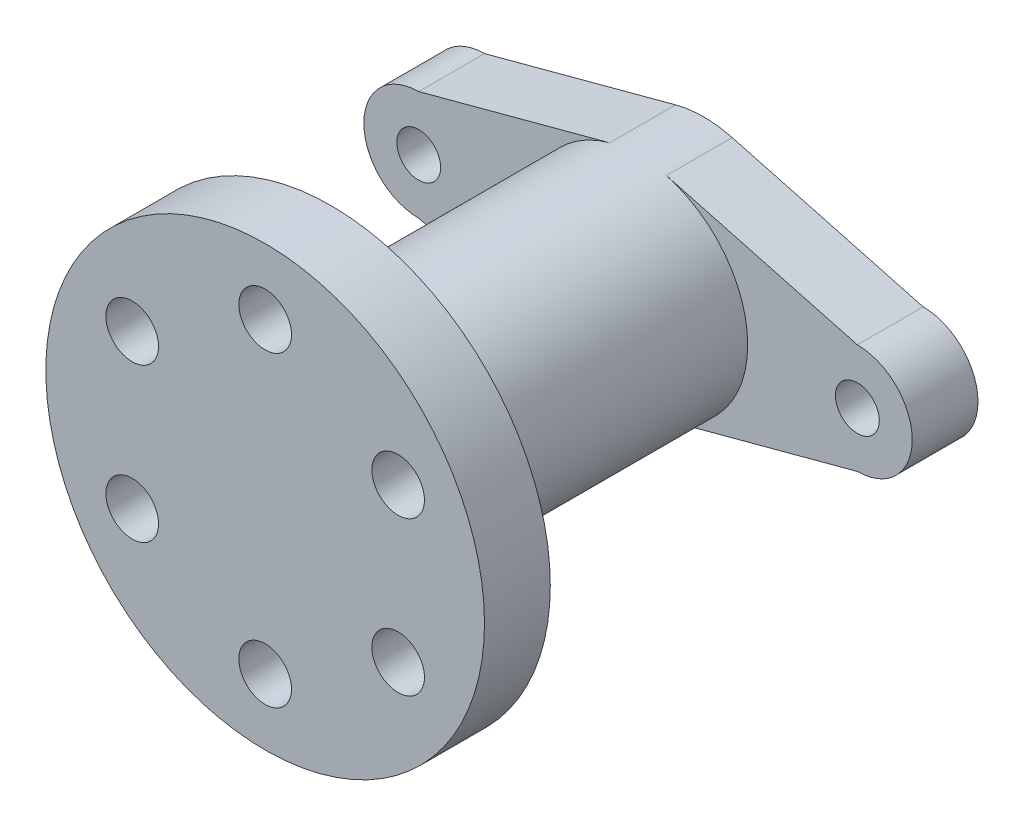
from build123d import *

# Parameters (mm, degrees)
SKETCH1_R           = 50
BOSS_EXTRUDE1_DEPTH = 15
SKETCH2_R           = 25
BOSS_EXTRUDE2_DEPTH = 70
BOSS_EXTRUDE3_DEPTH = 15
SKETCH5_R           = 15
CUT_EXTRUDE1_DEPTH  = 85
SKETCH6_R           = 5
CUT_EXTRUDE2_DEPTH  = 30
SKETCH7_R           = 6
CUT_EXTRUDE3_DEPTH  = 30


with BuildPart() as part:
    # Sketch1 → Boss-Extrude1 (new body)
    with BuildSketch(Plane.XY):
        Circle(SKETCH1_R)
    extrude(amount=BOSS_EXTRUDE1_DEPTH)

    # Sketch2 → Boss-Extrude2 (add)
    with BuildSketch(Plane(origin=(0, 0, 0), x_dir=(-1, 0, 0), z_dir=(0, 0, -1))):
        Circle(SKETCH2_R)
    extrude(amount=BOSS_EXTRUDE2_DEPTH)

    # Sketch4 → Boss-Extrude3 (add)
    with BuildSketch(Plane(origin=(0, 0, -70), x_dir=(-1, 0, 0), z_dir=(0, 0, -1))):
        with BuildLine():
            Line((-50, 12.5), (-6.462424595, 24.15030162))
            ThreePointArc((-6.462424595, 24.15030162), (0, 25), (6.462424595, 24.15030162))
            Line((6.462424595, 24.15030162), (50, 12.5))
            ThreePointArc((50, 12.5), (62.5, 0), (50, -12.5))
            Line((50, -12.5), (6.462424595, -24.15030162))
            ThreePointArc((6.462424595, -24.15030162), (0, -25), (-6.462424595, -24.15030162))
            Line((-6.462424595, -24.15030162), (-50, -12.5))
            ThreePointArc((-50, -12.5), (-62.5, 0), (-50, 12.5))
        make_face()
    extrude(amount=BOSS_EXTRUDE3_DEPTH)

    # Sketch5 → Cut-Extrude1 (cut)
    with BuildSketch(Plane(origin=(0, 0, -85), x_dir=(-1, 0, 0), z_dir=(0, 0, -1))):
        Circle(SKETCH5_R)
    extrude(amount=-CUT_EXTRUDE1_DEPTH, mode=Mode.SUBTRACT)

    # Sketch6 → Cut-Extrude2 (cut)
    with BuildSketch(Plane(origin=(0, 0, -85), x_dir=(-1, 0, 0), z_dir=(0, 0, -1))):
        with Locations((50, 0)):
            Circle(SKETCH6_R)
        with Locations((-50, 0)):
            Circle(SKETCH6_R)
    extrude(amount=-CUT_EXTRUDE2_DEPTH, mode=Mode.SUBTRACT)

    # Sketch7 → Cut-Extrude3 (cut)
    with BuildSketch(Plane(origin=(0, 0, 0), x_dir=(-1, 0, 0), z_dir=(0, 0, -1))):
        with Locations((0, 35)):
            Circle(SKETCH7_R)
        with Locations((30.310889132, 17.5)):
            Circle(SKETCH7_R)
        with Locations((30.310889132, -17.5)):
            Circle(SKETCH7_R)
        with Locations((0, -35)):
            Circle(SKETCH7_R)
        with Locations((-30.310889132, -17.5)):
            Circle(SKETCH7_R)
        with Locations((-30.310889132, 17.5)):
            Circle(SKETCH7_R)
    extrude(amount=-CUT_EXTRUDE3_DEPTH, mode=Mode.SUBTRACT)


solid = part.part
